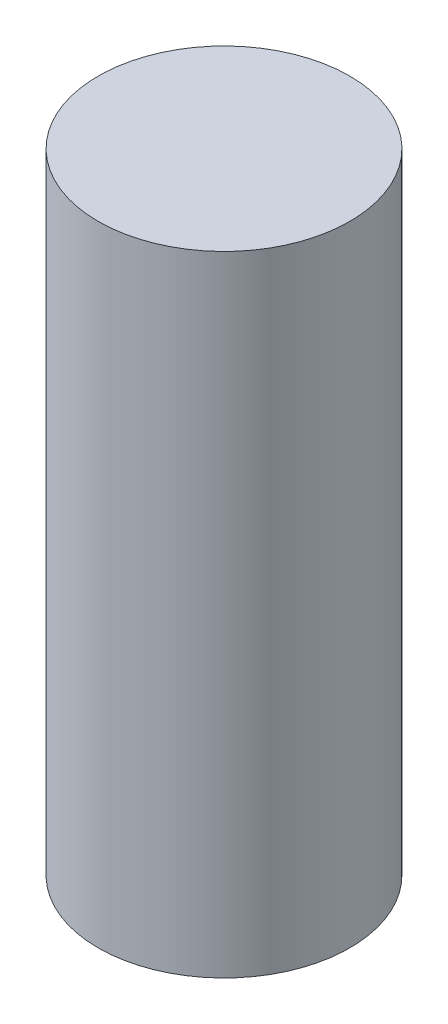
from build123d import *

# Parameters (mm, degrees)
SKETCH_1_R      = 3
EXTRUDE_1_DEPTH = 15


with BuildPart() as part:
    # Эскиз1 → Бобышка-Вытянуть1 (new body)
    with BuildSketch(Plane(origin=(0, 0, 0), x_dir=(1, 0, 0), z_dir=(0, 1, 0))):
        Circle(SKETCH_1_R)
    extrude(amount=EXTRUDE_1_DEPTH)


solid = part.part
